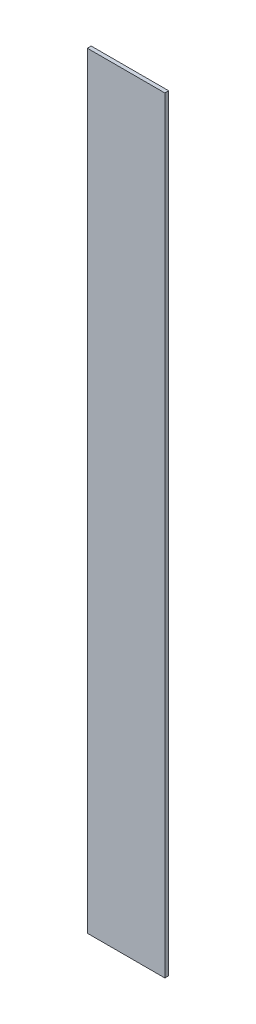
from build123d import *

# Parameters (mm, degrees)
SKETCH_1_W      = 60.658536585
SKETCH_1_H      = 3
EXTRUDE_1_DEPTH = 600


with BuildPart() as part:
    # 스케치1 → 보스-돌출1 (new body)
    with BuildSketch(Plane(origin=(0, 0, 0), x_dir=(1, 0, 0), z_dir=(0, 1, 0))):
        with Locations((30.329268293, 1.5)):
            Rectangle(SKETCH_1_W, SKETCH_1_H)
    extrude(amount=EXTRUDE_1_DEPTH)


solid = part.part
